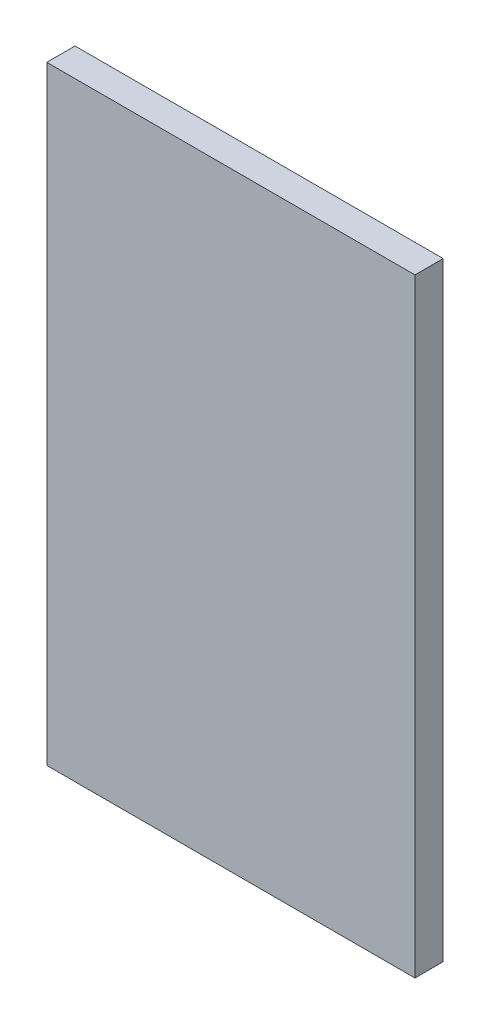
from build123d import *

# Parameters (mm, degrees)
SKETCH2_W           = 65.141850979
SKETCH2_H           = 107.735586507
BOSS_EXTRUDE1_DEPTH = 5


with BuildPart() as part:
    # Sketch2 → Boss-Extrude1 (new body)
    with BuildSketch(Plane.XY):
        with Locations((-0.156347237, 16.662344596)):
            Rectangle(SKETCH2_W, SKETCH2_H)
    extrude(amount=BOSS_EXTRUDE1_DEPTH)


solid = part.part
